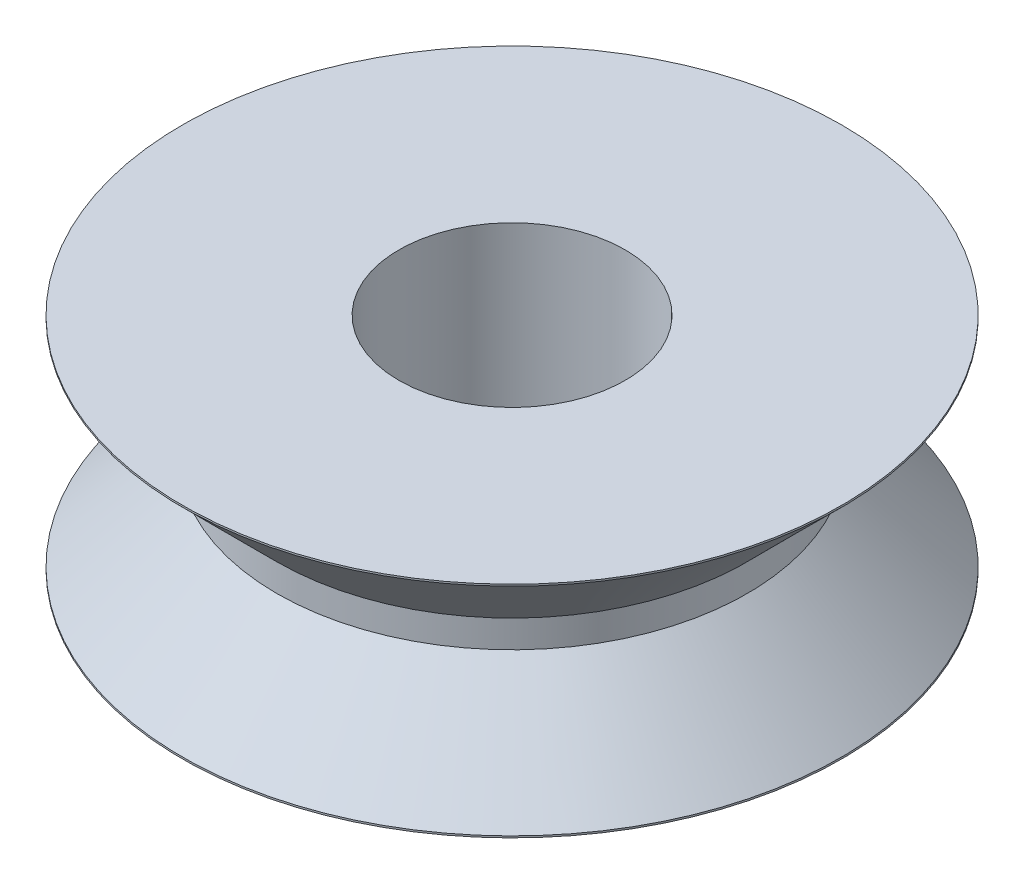
from build123d import *

# Parameters (mm, degrees)
SKETCH7_R          = 6.5405
CUT_EXTRUDE2_DEPTH = 13.7


with BuildPart() as part:
    # Sketch2 → Revolve1 (revolve)
    with BuildSketch(Plane.XY):
        Polygon((0, 0), (19.05, 0), (19.05, 0.1), (13.59375, 5.55625), (13.59375, 7.14375), (19.05, 12.6), (19.05, 12.7), (0, 12.7), align=None)
    revolve(axis=Axis((0, 0, 0), (0, 1, 0)))

    # Sketch7 → Cut-Extrude2 (cut, through all)
    with BuildSketch(Plane(origin=(0, 12.7, 0), x_dir=(1, 0, 0), z_dir=(0, 1, 0))):
        Circle(SKETCH7_R)
    extrude(amount=-CUT_EXTRUDE2_DEPTH, mode=Mode.SUBTRACT)


solid = part.part
